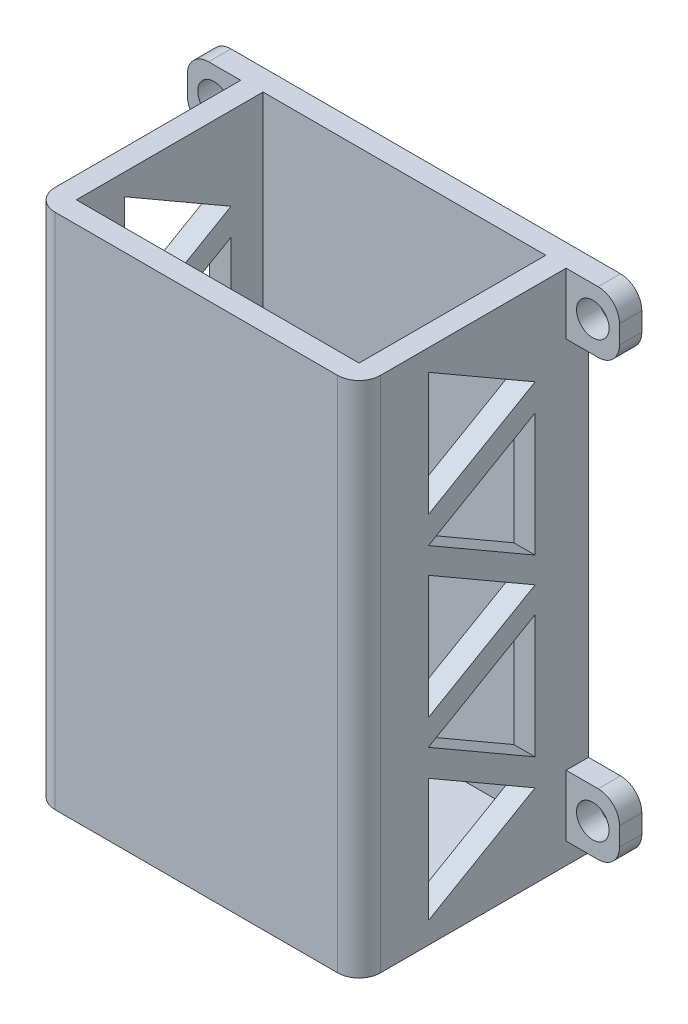
from build123d import *

# Parameters (mm, degrees)
SKETCH1_W               = 30.5
SKETCH1_H               = 21.5
SKETCH1_W_2             = 26.5
SKETCH1_H_2             = 17.5
BOSS_EXTRUDE1_DEPTH     = 46.5
FILLET1_R               = 2
SKETCH2_W               = 2.094102849
SKETCH2_H               = 5.748513101
BOSS_EXTRUDE2_DEPTH     = 5
CUT_EXTRUDE1_START      = -3.094102849
SKETCH3_R               = 1.525
CUT_EXTRUDE1_DEPTH      = 23.5
MIRROR4_COPY_1_SKETCH_W = 2.094102849
MIRROR4_COPY_1_SKETCH_H = 5.748513101
MIRROR4_COPY_1_DEPTH    = 5
MIRROR4_START           = -3.094102849
MIRROR4_COPY_2_SKETCH_R = 1.525
MIRROR4_COPY_2_DEPTH    = 23.5
FILLET2_R               = 2
BOSS_EXTRUDE4_DEPTH     = 2
CUT_EXTRUDE2_DEPTH      = 6
CUT_EXTRUDE2_DEPTH_BACK = 36.5


with BuildPart() as part:
    # Sketch1 → Boss-Extrude1 (new body)
    with BuildSketch(Plane(origin=(0, 0, 0), x_dir=(1, 0, 0), z_dir=(0, 1, 0))):
        Rectangle(SKETCH1_W, SKETCH1_H)
        Rectangle(SKETCH1_W_2, SKETCH1_H_2, mode=Mode.SUBTRACT)
    extrude(amount=BOSS_EXTRUDE1_DEPTH)

    # Fillet1
    fillet1_edges = [part.edges().sort_by_distance(p)[0] for p in [
        (-15.25, 23.25, 10.75),
        (15.25, 23.25, 10.75),
    ]]
    fillet(fillet1_edges, radius=FILLET1_R)

    # Sketch2 → Boss-Extrude2 (add)
    with BuildSketch(Plane.ZY.offset(15.25)):
        with Locations((-9.702948576, 2.874256551)):
            Rectangle(SKETCH2_W, SKETCH2_H)
    boss_extrude2 = extrude(amount=BOSS_EXTRUDE2_DEPTH)

    # Sketch3 → Cut-Extrude1 (cut)
    with BuildSketch(Plane.XY.offset(-8.655897151).offset(CUT_EXTRUDE1_START)):
        with Locations((-17.75, 2.874256551)):
            Circle(SKETCH3_R)
    cut_extrude1 = extrude(amount=CUT_EXTRUDE1_DEPTH, mode=Mode.SUBTRACT)

    # Mirror3: Boss-Extrude2, Cut-Extrude1 across plane
    add(boss_extrude2.mirror(Plane.ZX.offset(23.25)))
    add(cut_extrude1.mirror(Plane.ZX.offset(23.25)), mode=Mode.SUBTRACT)

    # Mirror4: Boss-Extrude2, Cut-Extrude1 across plane
    add(boss_extrude2.mirror(Plane(origin=(0, 0, 0), x_dir=(0, 0, 1), z_dir=(1, 0, 0))))
    add(cut_extrude1.mirror(Plane(origin=(0, 0, 0), x_dir=(0, 0, 1), z_dir=(1, 0, 0))), mode=Mode.SUBTRACT)

    # Mirror4 copy 1 sketch → Mirror4 copy 1 (add)
    with BuildSketch(Plane(origin=(15.25, 46.5, 0), x_dir=(0, 0, 1), z_dir=(1, 0, 0))):
        with Locations((-9.702948576, 2.874256551)):
            Rectangle(MIRROR4_COPY_1_SKETCH_W, MIRROR4_COPY_1_SKETCH_H)
    extrude(amount=MIRROR4_COPY_1_DEPTH)

    # Mirror4 copy 2 sketch → Mirror4 copy 2 (cut)
    with BuildSketch(Plane(origin=(0, 46.5, -8.655897151), x_dir=(-1, 0, 0), z_dir=(0, 0, 1)).offset(MIRROR4_START)):
        with Locations((-17.75, 2.874256551)):
            Circle(MIRROR4_COPY_2_SKETCH_R)
    extrude(amount=MIRROR4_COPY_2_DEPTH, mode=Mode.SUBTRACT)

    # Fillet2
    fillet2_edges = [part.edges().sort_by_distance(p)[0] for p in [
        (-20.25, 0, -9.702948576),
        (-20.25, 5.748513101, -9.702948576),
        (-20.25, 40.751486899, -9.702948576),
        (-20.25, 46.5, -9.702948576),
        (20.25, 46.5, -9.702948576),
        (20.25, 40.751486899, -9.702948576),
        (20.25, 5.748513101, -9.702948576),
        (20.25, 0, -9.702948576),
    ]]
    fillet(fillet2_edges, radius=FILLET2_R)

    # Sketch4 → Boss-Extrude4 (add)
    with BuildSketch(Plane.XZ):
        with BuildLine():
            Line((15.25, -10.75), (-15.25, -10.75))
            Line((-15.25, -10.75), (-15.25, 8.75))
            ThreePointArc((-15.25, 8.75), (-14.664213562, 10.164213562), (-13.25, 10.75))
            Line((-13.25, 10.75), (13.25, 10.75))
            ThreePointArc((13.25, 10.75), (14.664213562, 10.164213562), (15.25, 8.75))
            Line((15.25, 8.75), (15.25, -10.75))
        make_face()
    extrude(amount=BOSS_EXTRUDE4_DEPTH)

    # Sketch6 → Cut-Extrude2 (cut, two sides)
    with BuildSketch(Plane.ZY.offset(15.25)) as cut_extrude2_sk:
        Polygon((-5.75, 22.25), (4.25, 16.476497308), (4.25, 28.023502692), align=None)
        Polygon((-5.75, 38.726497308), (4.25, 32.952994616), (4.25, 44.5), align=None)
        Polygon((-5.75, 5.773502692), (4.25, 0), (4.25, 11.547005384), align=None)
        Polygon((4.25, 30.439180122), (-5.75, 36.212682814), (-5.75, 24.66567743), align=None)
        Polygon((-5.75, 19.83432257), (4.25, 14.060819878), (-5.75, 8.287317186), align=None)
    extrude(amount=CUT_EXTRUDE2_DEPTH, mode=Mode.SUBTRACT)
    extrude(cut_extrude2_sk.sketch, amount=-CUT_EXTRUDE2_DEPTH_BACK, mode=Mode.SUBTRACT)


solid = part.part
